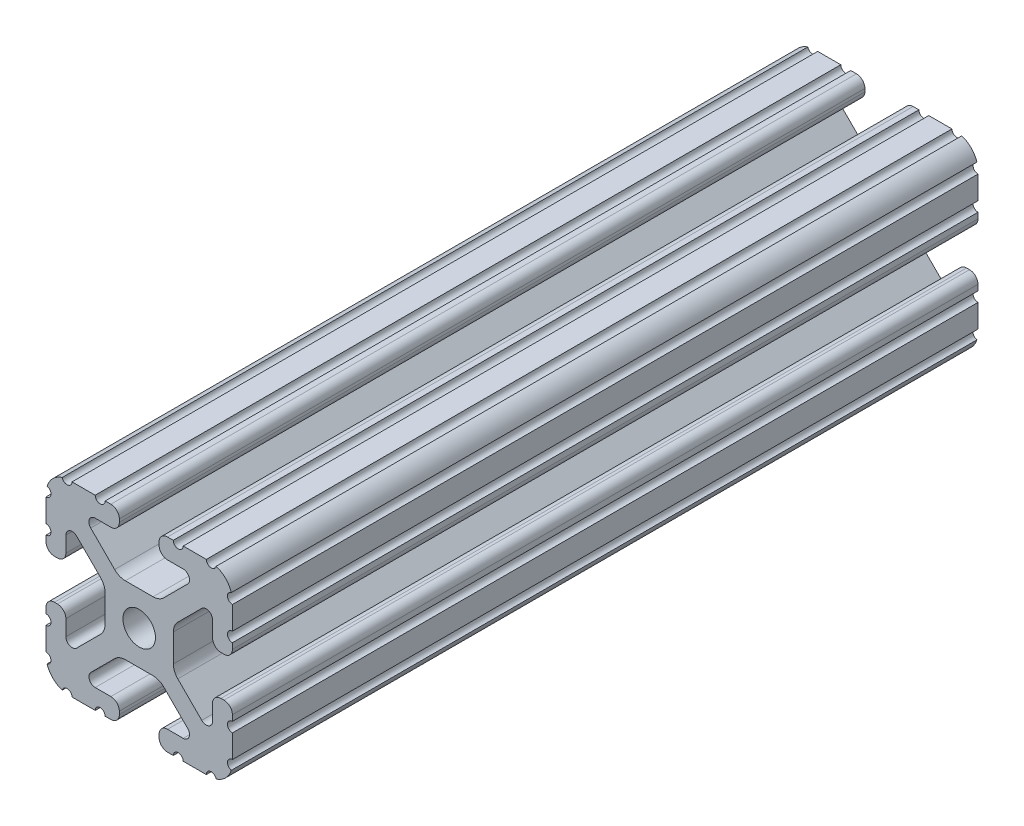
from build123d import *

# Parameters (mm, degrees)
BOSS_EXTRUDE1_DEPTH     = 76.2
SKETCH5_R               = 1.016
CUT_EXTRUDE1_DEPTH      = 77.2
CUT_EXTRUDE1_DEPTH_BACK = 77.2


with BuildPart() as part:
    # Sketch4 → Boss-Extrude1 (new body, symmetric)
    with BuildSketch(Plane.XY):
        with BuildLine():
            Line((5.7912, -19.05), (14.3002, -19.05))
            ThreePointArc((14.3002, -19.05), (17.658815789, -17.658815789), (19.05, -14.3002))
            Line((19.05, -14.3002), (19.05, -5.7912))
            ThreePointArc((19.05, -5.7912), (18.544114832, -4.569885168), (17.3228, -4.064))
            Line((17.3228, -4.064), (16.7132, -4.064))
            ThreePointArc((16.7132, -4.064), (15.491885168, -4.569885168), (14.986, -5.7912))
            Line((14.986, -5.7912), (14.986, -8.996305235))
            ThreePointArc((14.986, -8.996305235), (14.189232738, -10.188751711), (12.782646215, -9.908964256))
            Line((12.782646215, -9.908964256), (7.888897763, -5.015215804))
            ThreePointArc((7.888897763, -5.015215804), (7.219915375, -4.014012907), (6.985, -2.833013566))
            Line((6.985, -2.833013566), (6.985, 0))
            Line((6.985, 0), (3.3274, 0))
            ThreePointArc((3.3274, 0), (2.352827104, -2.352827104), (0, -3.3274))
            Line((0, -3.3274), (0, -6.985))
            Line((0, -6.985), (2.833013566, -6.985))
            ThreePointArc((2.833013566, -6.985), (4.014012907, -7.219915375), (5.015215804, -7.888897763))
            Line((5.015215804, -7.888897763), (9.908964256, -12.782646215))
            ThreePointArc((9.908964256, -12.782646215), (10.188751711, -14.189232738), (8.996305235, -14.986))
            Line((8.996305235, -14.986), (5.7912, -14.986))
            ThreePointArc((5.7912, -14.986), (4.569885168, -15.491885168), (4.064, -16.7132))
            Line((4.064, -16.7132), (4.064, -17.3228))
            ThreePointArc((4.064, -17.3228), (4.569885168, -18.544114832), (5.7912, -19.05))
        make_face()
    extrude(amount=BOSS_EXTRUDE1_DEPTH, both=True)

    # Sketch5 → Cut-Extrude1 (cut, two sides)
    with BuildSketch(Plane.XY) as cut_extrude1_sk:
        with Locations((14.739477062, -19.05)):
            Circle(SKETCH5_R)
        with Locations((7.980305235, -19.05)):
            Circle(SKETCH5_R)
        with Locations((19.05, -14.739477062)):
            Circle(SKETCH5_R)
        with Locations((19.05, -7.980305235)):
            Circle(SKETCH5_R)
    extrude(amount=CUT_EXTRUDE1_DEPTH, mode=Mode.SUBTRACT)
    extrude(cut_extrude1_sk.sketch, amount=-CUT_EXTRUDE1_DEPTH_BACK, mode=Mode.SUBTRACT)

    # Mirror1: part across plane


with BuildPart() as part_1:
    add(part.part)
    add(part.part.mirror(Plane(origin=(0, 0, 0), x_dir=(0, 0, 1), z_dir=(1, 0, 0))))

    # Mirror2: part across plane


with BuildPart() as part_2:
    add(part_1.part)
    add(part_1.part.mirror(Plane.ZX))


solid = part_2.part
